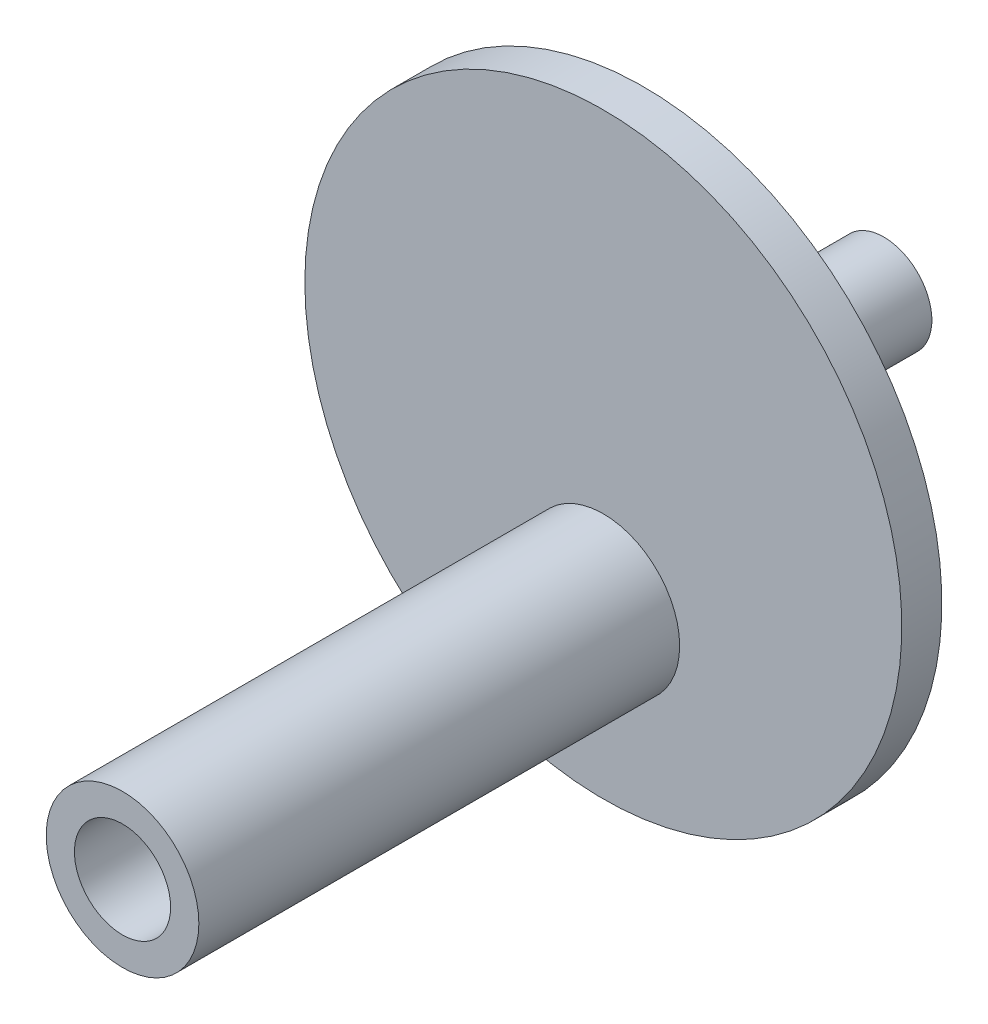
from build123d import *

# Parameters (mm, degrees)
SKETCH2_R           = 9.525
SKETCH2_R_2         = 6
BOSS_EXTRUDE1_DEPTH = 60


with BuildPart() as part:
    # Sketch1 → Revolve1 (revolve)
    with BuildSketch(Plane(origin=(0, 0, 0), x_dir=(0, 0, -1), z_dir=(1, 0, 0))):
        Polygon((0, 8), (0, 37.25), (-5, 37.25), (-5, 0), (30, 0), (30, 6), (15.1, 6), (15.1, 8), align=None)
    revolve(axis=Axis((0, 0, -30), (0, 0, 1)))

    # Sketch2 → Boss-Extrude1 (add)
    with BuildSketch(Plane.XY.offset(5)):
        with Locations((0, -15.9375)):
            Circle(SKETCH2_R)
        with Locations((0, -15.9375)):
            Circle(SKETCH2_R_2, mode=Mode.SUBTRACT)
    extrude(amount=BOSS_EXTRUDE1_DEPTH)


solid = part.part
